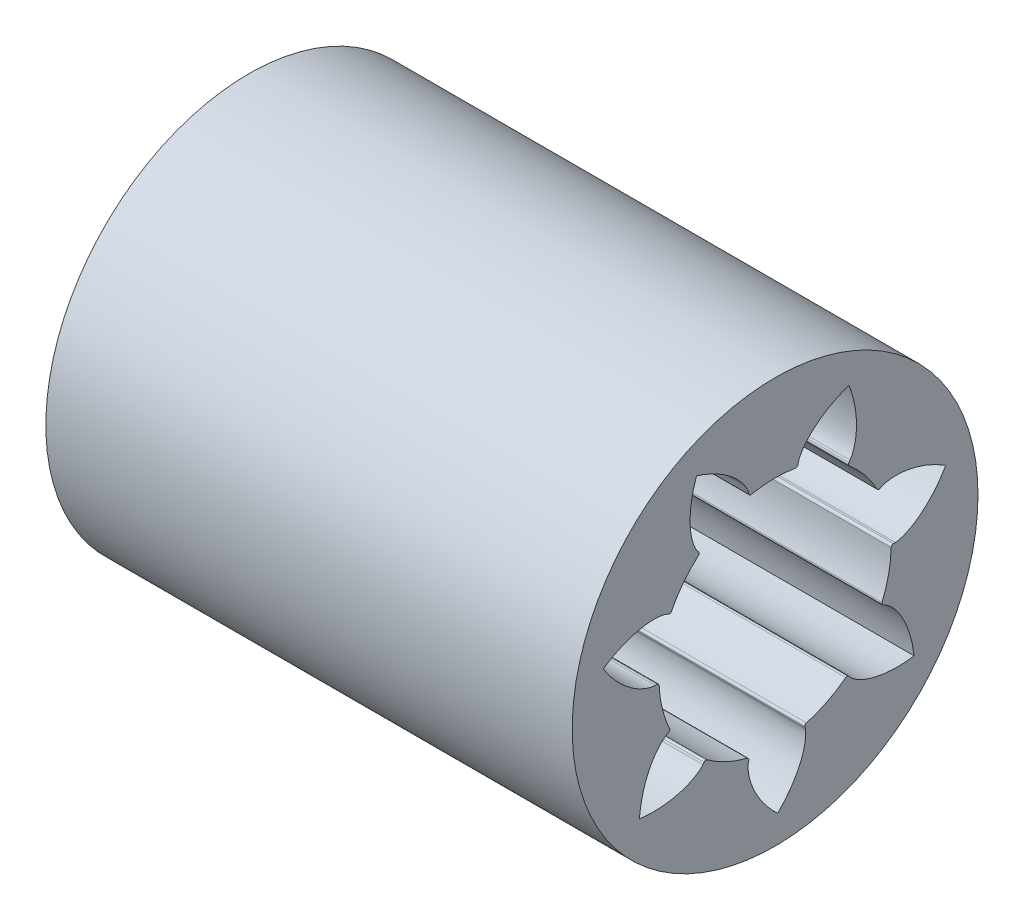
from build123d import *

# Parameters (mm, degrees)
SKETCH1_R           = 11.0998
SKETCH1_R_2         = 6.35
BOSS_EXTRUDE1_DEPTH = 28.7909
CUT_EXTRUDE1_DEPTH  = 29.7909


with BuildPart() as part:
    # Sketch1 → Boss-Extrude1 (new body)
    with BuildSketch(Plane(origin=(0, 0, 0), x_dir=(0, 0, -1), z_dir=(1, 0, 0))):
        Circle(SKETCH1_R)
        Circle(SKETCH1_R_2, mode=Mode.SUBTRACT)
    extrude(amount=BOSS_EXTRUDE1_DEPTH)

    # Sketch2 → Cut-Extrude1 (cut, through all)
    with BuildSketch(Plane(origin=(28.7909, 0, 0), x_dir=(0, 0, -1), z_dir=(1, 0, 0))):
        with BuildLine():
            Line((6.474130281, -0.001158176), (6.578185303, -0.001158176))
            add(Edge.make_bspline(
                [(9.33725198, 2.277109523), (9.026788871, 1.745877342), (8.645958112, 1.252954589), (7.959182142, 0.63636838), (7.710996197, 0.451363279), (7.308736017, 0.225206881), (7.169652145, 0.1583894), (6.953463656, 0.077752246), (6.880140329, 0.054136843), (6.768281417, 0.025899435), (6.730682721, 0.017680544), (6.654875253, 0.004690568), (6.616647596, -0.001158176), (6.578185303, -0.001158176)],
                knots=[0, 0, 0, 0, 0.5, 0.5, 0.75, 0.75, 0.875, 0.875, 0.9375, 0.9375, 0.96875, 0.96875, 1, 1, 1, 1], degree=3))
            add(Edge.make_bspline(
                [(5.839078461, 3.028228975), (5.873216938, 3.045941468), (5.909837407, 3.058361857), (5.983101693, 3.081751648), (6.020257835, 3.091774788), (6.132542366, 3.118237286), (6.208496722, 3.131051512), (6.437512921, 3.159063938), (6.591731079, 3.163826247), (7.052919967, 3.148396063), (7.358408867, 3.098520105), (8.25195477, 2.867633415), (8.817005427, 2.605577754), (9.33725198, 2.277109523)],
                knots=[0, 0, 0, 0, 0.03125, 0.03125, 0.0625, 0.0625, 0.125, 0.125, 0.25, 0.25, 0.5, 0.5, 1, 1, 1, 1], degree=3))
            Line((5.839078461, 3.028228975), (5.746715375, 2.980307082))
            ThreePointArc((5.746715375, 2.980307082), (5.652549378, 2.971739386), (5.579324806, 3.031562479))
            ThreePointArc((5.579324806, 3.031562479), (4.905408798, 4.031554338), (4.054601648, 4.886114867))
            ThreePointArc((4.054601648, 4.886114867), (4.01006667, 4.969525155), (4.036681073, 5.060257255))
            Line((4.036681073, 5.060257255), (4.101558318, 5.141610747))
            add(Edge.make_bspline(
                [(4.040586842, 8.719212614), (4.262350302, 8.145264934), (4.410288734, 7.540187147), (4.464157431, 6.618808859), (4.454058838, 6.309420481), (4.380069909, 5.8539146), (4.345592545, 5.703514431), (4.273845892, 5.484215022), (4.246592811, 5.412164574), (4.198926814, 5.307104019), (4.181910199, 5.272583779), (4.144800988, 5.205215997), (4.125539166, 5.171681779), (4.101558318, 5.141610747)],
                knots=[0, 0, 0, 0, 0.5, 0.5, 0.75, 0.75, 0.875, 0.875, 0.9375, 0.9375, 0.96875, 0.96875, 1, 1, 1, 1], degree=3))
            add(Edge.make_bspline(
                [(1.272262492, 6.452545744), (1.2796993, 6.490279838), (1.292821138, 6.52665486), (1.320213798, 6.598518481), (1.335543867, 6.633817648), (1.384862913, 6.738104328), (1.422201114, 6.805477374), (1.543089382, 7.00199491), (1.635519508, 7.125536772), (1.93512988, 7.476488202), (2.164593688, 7.68423189), (2.902224929, 8.238878712), (3.459411617, 8.517264072), (4.040586842, 8.719212614)],
                knots=[0, 0, 0, 0, 0.03125, 0.03125, 0.0625, 0.0625, 0.125, 0.125, 0.25, 0.25, 0.5, 0.5, 1, 1, 1, 1], degree=3))
            Line((1.272262492, 6.452545744), (1.252141895, 6.350454563))
            ThreePointArc((1.252141895, 6.350454563), (1.20012885, 6.271490752), (1.107702498, 6.251540565))
            ThreePointArc((1.107702498, 6.251540565), (-0.094302378, 6.348136539), (-1.292894285, 6.215758499))
            ThreePointArc((-1.292894285, 6.215758499), (-1.385874176, 6.232945116), (-1.440217579, 6.31032363))
            Line((-1.440217579, 6.31032363), (-1.463372001, 6.411769776))
            add(Edge.make_bspline(
                [(-4.298468866, 8.594698635), (-3.711471244, 8.410229765), (-3.146164277, 8.14863286), (-2.392215142, 7.616279136), (-2.156621936, 7.415483239), (-1.846624441, 7.073633094), (-1.75053314, 6.952904634), (-1.623811263, 6.760079896), (-1.584471973, 6.69384986), (-1.532051586, 6.591078898), (-1.515672262, 6.556251756), (-1.486139224, 6.485235481), (-1.471930666, 6.44926774), (-1.463372001, 6.411769776)],
                knots=[0, 0, 0, 0, 0.5, 0.5, 0.75, 0.75, 0.875, 0.875, 0.9375, 0.9375, 0.96875, 0.96875, 1, 1, 1, 1], degree=3))
            add(Edge.make_bspline(
                [(-4.252339347, 5.017091827), (-4.277204276, 5.046432981), (-4.297462081, 5.079371502), (-4.336568278, 5.145594181), (-4.354608136, 5.179588382), (-4.405392823, 5.283169246), (-4.434787204, 5.354367835), (-4.513058199, 5.571408768), (-4.552017875, 5.720700642), (-4.639598741, 6.1737601), (-4.658950952, 6.482688201), (-4.632685742, 7.405208164), (-4.502935963, 8.014404692), (-4.298468866, 8.594698635)],
                knots=[0, 0, 0, 0, 0.03125, 0.03125, 0.0625, 0.0625, 0.125, 0.125, 0.25, 0.25, 0.5, 0.5, 1, 1, 1, 1], degree=3))
            Line((-4.252339347, 5.017091827), (-4.185066235, 4.9377081))
            ThreePointArc((-4.185066235, 4.9377081), (-4.155759444, 4.847809533), (-4.197788648, 4.763108964))
            ThreePointArc((-4.197788648, 4.763108964), (-5.022748202, 3.883570316), (-5.666560713, 2.863937072))
            ThreePointArc((-5.666560713, 2.863937072), (-5.737969765, 2.801958143), (-5.832349283, 2.807715474))
            Line((-5.832349283, 2.807715474), (-5.926099619, 2.852863258))
            add(Edge.make_bspline(
                [(-9.400436108, 1.997329154), (-8.890225506, 2.341247916), (-8.333237682, 2.620119697), (-7.446947184, 2.87766375), (-7.143068669, 2.936663741), (-6.682519186, 2.965889463), (-6.528217929, 2.965743704), (-6.298451681, 2.944594599), (-6.222143307, 2.934057542), (-6.109110157, 2.910964804), (-6.071668859, 2.902056307), (-5.997732551, 2.880868243), (-5.960752948, 2.869551421), (-5.926099619, 2.852863258)],
                knots=[0, 0, 0, 0, 0.5, 0.5, 0.75, 0.75, 0.875, 0.875, 0.9375, 0.9375, 0.96875, 0.96875, 1, 1, 1, 1], degree=3))
            add(Edge.make_bspline(
                [(-6.574589188, -0.197206695), (-6.613032056, -0.198352969), (-6.651414964, -0.193654327), (-6.727572254, -0.182939618), (-6.765397659, -0.17584871), (-6.878044173, -0.150972164), (-6.952036568, -0.129562023), (-7.170527169, -0.055433942), (-7.311539218, 0.007188117), (-7.720361142, 0.221192591), (-7.973956763, 0.398675943), (-8.678835823, 0.9943927), (-9.074227184, 1.475662984), (-9.400436108, 1.997329154)],
                knots=[0, 0, 0, 0, 0.03125, 0.03125, 0.0625, 0.0625, 0.125, 0.125, 0.25, 0.25, 0.5, 0.5, 1, 1, 1, 1], degree=3))
            Line((-6.574589188, -0.197206695), (-6.470580392, -0.194105403))
            ThreePointArc((-6.470580392, -0.194105403), (-6.382022378, -0.227243272), (-6.342005586, -0.312912967))
            ThreePointArc((-6.342005586, -0.312912967), (-6.16870845, -1.506275696), (-5.772937614, -2.645359515))
            ThreePointArc((-5.772937614, -2.645359515), (-5.769003353, -2.73983259), (-5.832349284, -2.810031831))
            Line((-5.832349284, -2.810031831), (-5.92609962, -2.855179612))
            add(Edge.make_bspline(
                [(-7.423429493, -6.104942048), (-7.374204901, -5.491613497), (-7.244959411, -4.882269169), (-6.893722373, -4.028763264), (-6.750385268, -3.754395582), (-6.486086952, -3.376101557), (-6.389767732, -3.255554856), (-6.229975784, -3.089102621), (-6.174160088, -3.036012079), (-6.085630443, -2.962037291), (-6.055321231, -2.938318862), (-5.992657202, -2.893723671), (-5.960752949, -2.871867776), (-5.92609962, -2.855179612)],
                knots=[0, 0, 0, 0, 0.5, 0.5, 0.75, 0.75, 0.875, 0.875, 0.9375, 0.9375, 0.96875, 0.96875, 1, 1, 1, 1], degree=3))
            add(Edge.make_bspline(
                [(-3.94578554, -5.263876684), (-3.968858083, -5.294647218), (-3.996462981, -5.321726629), (-4.052323372, -5.374588284), (-4.081451021, -5.399740267), (-4.171134241, -5.472300586), (-4.234006867, -5.516801165), (-4.428189196, -5.641405894), (-4.565068667, -5.712609337), (-4.987280403, -5.898809581), (-5.284156759, -5.986419561), (-6.18939178, -6.166092879), (-6.812186521, -6.175155179), (-7.423429493, -6.104942048)],
                knots=[0, 0, 0, 0, 0.03125, 0.03125, 0.0625, 0.0625, 0.125, 0.125, 0.25, 0.25, 0.5, 0.5, 1, 1, 1, 1], degree=3))
            Line((-3.94578554, -5.263876684), (-3.883361806, -5.18062571))
            ThreePointArc((-3.883361806, -5.18062571), (-3.802238558, -5.132049389), (-3.710309231, -5.154177183))
            ThreePointArc((-3.710309231, -5.154177183), (-2.669251682, -5.762737518), (-1.531921011, -6.163518563))
            ThreePointArc((-1.531921011, -6.163518563), (-1.455606014, -6.219345633), (-1.44021758, -6.312639988))
            Line((-1.44021758, -6.312639988), (-1.463372001, -6.414086132))
            add(Edge.make_bspline(
                [(0.143824676, -9.610939504), (-0.305003864, -9.190050072), (-0.700825198, -8.709081904), (-1.149130273, -7.902321502), (-1.274270342, -7.61919059), (-1.405245216, -7.176691379), (-1.439438371, -7.026226341), (-1.469947318, -6.797514694), (-1.476654658, -6.720774815), (-1.479293145, -6.605437025), (-1.478939475, -6.566952131), (-1.474735017, -6.490154773), (-1.471930667, -6.451584096), (-1.463372001, -6.414086132)],
                knots=[0, 0, 0, 0, 0.5, 0.5, 0.75, 0.75, 0.875, 0.875, 0.9375, 0.9375, 0.96875, 0.96875, 1, 1, 1, 1], degree=3))
            add(Edge.make_bspline(
                [(1.654528834, -6.3676123), (1.664200712, -6.404836254), (1.668160875, -6.443302369), (1.674661397, -6.519934484), (1.676165217, -6.558389402), (1.676978586, -6.673747186), (1.672570099, -6.750648641), (1.648919296, -6.980156277), (1.619245435, -7.131567578), (1.501577937, -7.577759958), (1.384974797, -7.864491169), (0.96104425, -8.684256889), (0.579823271, -9.176827676), (0.143824676, -9.610939504)],
                knots=[0, 0, 0, 0, 0.03125, 0.03125, 0.0625, 0.0625, 0.125, 0.125, 0.25, 0.25, 0.5, 0.5, 1, 1, 1, 1], degree=3))
            Line((1.654528834, -6.3676123), (1.628361162, -6.266901324))
            ThreePointArc((1.628361162, -6.266901324), (1.640962184, -6.173189774), (1.715579387, -6.115112987))
            ThreePointArc((1.715579387, -6.115112987), (2.840459782, -5.680612583), (3.862917095, -5.041294552))
            ThreePointArc((3.862917095, -5.041294552), (3.954146078, -5.016436695), (4.036681073, -5.06257361))
            Line((4.036681073, -5.06257361), (4.101558318, -5.143927101))
            add(Edge.make_bspline(
                [(7.603029666, -5.880575616), (6.99412504, -5.96906363), (6.37129842, -5.978650462), (5.461034096, -5.826142601), (5.161649878, -5.74745181), (4.734028566, -5.573958344), (4.59507118, -5.506878213), (4.397235196, -5.388131689), (4.333055585, -5.345529166), (4.241235799, -5.275680083), (4.211367607, -5.251408634), (4.153946452, -5.200239086), (4.125539166, -5.173998133), (4.101558318, -5.143927101)],
                knots=[0, 0, 0, 0, 0.5, 0.5, 0.75, 0.75, 0.875, 0.875, 0.9375, 0.9375, 0.96875, 0.96875, 1, 1, 1, 1], degree=3))
            add(Edge.make_bspline(
                [(6.009202987, -2.677278108), (6.044336163, -2.692925086), (6.076879304, -2.713812136), (6.140845713, -2.756509165), (6.171848596, -2.779309681), (6.26254607, -2.850598165), (6.319921402, -2.901992132), (6.484611663, -3.063578745), (6.584488435, -3.181182105), (6.8599712, -3.551374659), (7.011445819, -3.82131265), (7.388048094, -4.663870464), (7.53546805, -5.26903389), (7.603029666, -5.880575616)],
                knots=[0, 0, 0, 0, 0.03125, 0.03125, 0.0625, 0.0625, 0.125, 0.125, 0.25, 0.25, 0.5, 0.5, 1, 1, 1, 1], degree=3))
            Line((6.009202987, -2.677278108), (5.9141487, -2.634944551))
            ThreePointArc((5.9141487, -2.634944551), (5.848738668, -2.566664481), (5.849855471, -2.472116118))
            ThreePointArc((5.849855471, -2.472116118), (6.211500831, -1.32174264), (6.349153575, -0.12374505))
            ThreePointArc((6.349153575, -0.12374505), (6.386599259, -0.036920737), (6.474130281, -0.001158176))
        make_face()
    extrude(amount=-CUT_EXTRUDE1_DEPTH, mode=Mode.SUBTRACT)


solid = part.part
